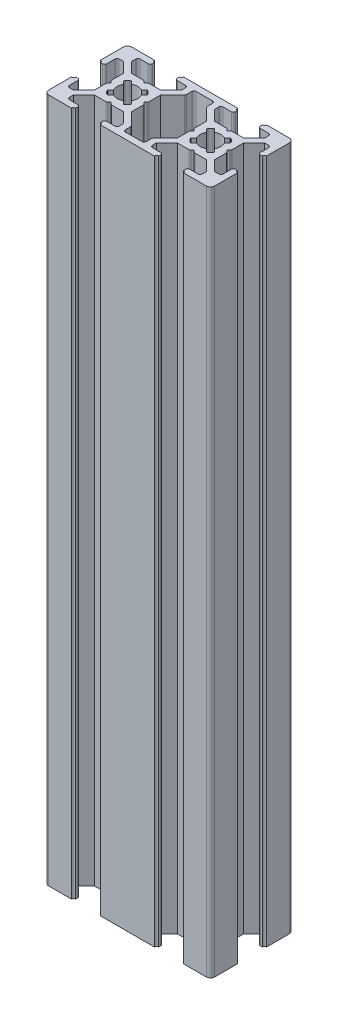
from build123d import *

# Parameters (mm, degrees)
BOSS_EXTRUDE1_DEPTH = 165
FILLET1_R           = 1
FILLET2_R           = 0.5
FILLET3_R           = 0.25
FILLET5_R           = 0.25
FILLET6_R           = 0.5
FILLET7_R           = 0.5
FILLET8_R           = 0.5


with BuildPart() as part:
    # Sketch2 → Boss-Extrude1 (new body)
    with BuildSketch(Plane(origin=(0, 0, 0), x_dir=(1, 0, 0), z_dir=(0, 1, 0))):
        with BuildLine():
            ThreePointArc((0, 13.5), (0.353553391, 13.353553391), (0.5, 13))
            Line((0.5, 13), (1.5, 13))
            Line((1.5, 13), (1.5, 16))
            Line((1.5, 16), (3, 16))
            Line((3, 16), (5.5, 13.5))
            Line((5.5, 13.5), (5.5, 10.5))
            Line((5.5, 10.5), (6, 10))
            Line((6, 10), (5.5, 9.5))
            Line((5.5, 9.5), (5.5, 6.5))
            Line((5.5, 6.5), (3, 4))
            Line((3, 4), (1.5, 4))
            Line((1.5, 4), (1.5, 7))
            Line((1.5, 7), (0.5, 7))
            ThreePointArc((0.5, 7), (0.353553391, 6.646446609), (0, 6.5))
            Line((0, 6.5), (0, 0))
            Line((0, 0), (6.5, 0))
            ThreePointArc((6.5, 0), (6.646446609, 0.353553391), (7, 0.5))
            Line((7, 0.5), (7, 1.5))
            Line((7, 1.5), (4, 1.5))
            Line((4, 1.5), (4, 3))
            Line((4, 3), (6.5, 5.5))
            Line((6.5, 5.5), (9.5, 5.5))
            Line((9.5, 5.5), (10, 6))
            Line((10, 6), (10.5, 5.5))
            Line((10.5, 5.5), (13.5, 5.5))
            Line((13.5, 5.5), (16, 3))
            Line((16, 3), (16, 1.5))
            Line((16, 1.5), (13, 1.5))
            Line((13, 1.5), (13, 0.5))
            ThreePointArc((13, 0.5), (13.353553391, 0.353553391), (13.5, 0))
            Line((13.5, 0), (26.5, 0))
            ThreePointArc((26.5, 0), (26.646446609, 0.353553391), (27, 0.5))
            Line((27, 0.5), (27, 1.5))
            Line((27, 1.5), (24, 1.5))
            Line((24, 1.5), (24, 3))
            Line((24, 3), (26.5, 5.5))
            Line((26.5, 5.5), (29.5, 5.5))
            Line((29.5, 5.5), (30, 6))
            Line((30, 6), (30.5, 5.5))
            Line((30.5, 5.5), (33.5, 5.5))
            Line((33.5, 5.5), (36, 3))
            Line((36, 3), (36, 1.5))
            Line((36, 1.5), (33, 1.5))
            Line((33, 1.5), (33, 0.5))
            ThreePointArc((33, 0.5), (33.353553391, 0.353553391), (33.5, 0))
            Line((33.5, 0), (40, 0))
            Line((40, 0), (40, 6.5))
            ThreePointArc((40, 6.5), (39.646446609, 6.646446609), (39.5, 7))
            Line((39.5, 7), (38.5, 7))
            Line((38.5, 7), (38.5, 4))
            Line((38.5, 4), (37, 4))
            Line((37, 4), (34.5, 6.5))
            Line((34.5, 6.5), (34.5, 9.5))
            Line((34.5, 9.5), (34, 10))
            Line((34, 10), (34.5, 10.5))
            Line((34.5, 10.5), (34.5, 13.5))
            Line((34.5, 13.5), (37, 16))
            Line((37, 16), (38.5, 16))
            Line((38.5, 16), (38.5, 13))
            Line((38.5, 13), (39.5, 13))
            ThreePointArc((39.5, 13), (39.646446609, 13.353553391), (40, 13.5))
            Line((40, 13.5), (40, 20))
            Line((40, 20), (33.5, 20))
            ThreePointArc((33.5, 20), (33.353553391, 19.646446609), (33, 19.5))
            Line((33, 19.5), (33, 18.5))
            Line((33, 18.5), (36, 18.5))
            Line((36, 18.5), (36, 17))
            Line((36, 17), (33.5, 14.5))
            Line((33.5, 14.5), (30.5, 14.5))
            Line((30.5, 14.5), (30, 14))
            Line((30, 14), (29.5, 14.5))
            Line((29.5, 14.5), (26.5, 14.5))
            Line((26.5, 14.5), (24, 17))
            Line((24, 17), (24, 18.5))
            Line((24, 18.5), (27, 18.5))
            Line((27, 18.5), (27, 19.5))
            ThreePointArc((27, 19.5), (26.646446609, 19.646446609), (26.5, 20))
            Line((26.5, 20), (13.5, 20))
            ThreePointArc((13.5, 20), (13.353553391, 19.646446609), (13, 19.5))
            Line((13, 19.5), (13, 18.5))
            Line((13, 18.5), (16, 18.5))
            Line((16, 18.5), (16, 17))
            Line((16, 17), (13.5, 14.5))
            Line((13.5, 14.5), (10.5, 14.5))
            Line((10.5, 14.5), (10, 14))
            Line((10, 14), (9.5, 14.5))
            Line((9.5, 14.5), (6.5, 14.5))
            Line((6.5, 14.5), (4, 17))
            Line((4, 17), (4, 18.5))
            Line((4, 18.5), (7, 18.5))
            Line((7, 18.5), (7, 19.5))
            ThreePointArc((7, 19.5), (6.646446609, 19.646446609), (6.5, 20))
            Line((6.5, 20), (0, 20))
            Line((0, 20), (0, 13.5))
        make_face()
        with BuildLine():
            Line((11.195582496, 12.195582496), (12, 13))
            Line((12, 13), (13, 12))
            Line((13, 12), (12.195582496, 11.195582496))
            ThreePointArc((12.195582496, 11.195582496), (12.422700584, 10.616864556), (12.5, 10))
            ThreePointArc((12.5, 10), (12.422700584, 9.383135444), (12.195582496, 8.804417504))
            Line((12.195582496, 8.804417504), (13, 8))
            Line((13, 8), (12, 7))
            Line((12, 7), (11.195582496, 7.804417504))
            ThreePointArc((11.195582496, 7.804417504), (10, 7.5), (8.804417504, 7.804417504))
            Line((8.804417504, 7.804417504), (8, 7))
            Line((8, 7), (7, 8))
            Line((7, 8), (7.804417504, 8.804417504))
            ThreePointArc((7.804417504, 8.804417504), (7.5, 10), (7.804417504, 11.195582496))
            Line((7.804417504, 11.195582496), (7, 12))
            Line((7, 12), (8, 13))
            Line((8, 13), (8.804417504, 12.195582496))
            ThreePointArc((8.804417504, 12.195582496), (10, 12.5), (11.195582496, 12.195582496))
        make_face(mode=Mode.SUBTRACT)
        Polygon((17.5, 16.5), (17.5, 18.5), (22.5, 18.5), (22.5, 16.5), (25.5, 13.5), (25.5, 10.5), (26, 10), (25.5, 9.5), (25.5, 6.5), (22.5, 3.5), (22.5, 1.5), (17.5, 1.5), (17.5, 3.5), (14.5, 6.5), (14.5, 9.5), (14, 10), (14.5, 10.5), (14.5, 13.5), align=None, mode=Mode.SUBTRACT)
        with BuildLine():
            Line((28.804417504, 7.804417504), (28, 7))
            Line((28, 7), (27, 8))
            Line((27, 8), (27.804417504, 8.804417504))
            ThreePointArc((27.804417504, 8.804417504), (27.5, 10), (27.804417504, 11.195582496))
            Line((27.804417504, 11.195582496), (27, 12))
            Line((27, 12), (28, 13))
            Line((28, 13), (28.804417504, 12.195582496))
            ThreePointArc((28.804417504, 12.195582496), (30, 12.5), (31.195582496, 12.195582496))
            Line((31.195582496, 12.195582496), (32, 13))
            Line((32, 13), (33, 12))
            Line((33, 12), (32.195582496, 11.195582496))
            ThreePointArc((32.195582496, 11.195582496), (32.422700584, 10.616864556), (32.5, 10))
            ThreePointArc((32.5, 10), (32.422700584, 9.383135444), (32.195582496, 8.804417504))
            Line((32.195582496, 8.804417504), (33, 8))
            Line((33, 8), (32, 7))
            Line((32, 7), (31.195582496, 7.804417504))
            ThreePointArc((31.195582496, 7.804417504), (30, 7.5), (28.804417504, 7.804417504))
        make_face(mode=Mode.SUBTRACT)
    extrude(amount=BOSS_EXTRUDE1_DEPTH)

    # Fillet1
    fillet1_edges = [part.edges().sort_by_distance(p)[0] for p in [
        (40, 82.5, 0),
        (0, 82.5, 0),
        (0, 82.5, -20),
        (40, 82.5, -20),
    ]]
    fillet(fillet1_edges, radius=FILLET1_R)

    # Fillet2
    fillet2_edges = [part.edges().sort_by_distance(p)[0] for p in [
        (7, 82.5, -18.5),
        (4, 82.5, -18.5),
        (9.5, 82.5, -14.5),
        (10.5, 82.5, -14.5),
        (16, 82.5, -18.5),
        (13, 82.5, -18.5),
    ]]
    fillet(fillet2_edges, radius=FILLET2_R)

    # Fillet3
    fillet3_edges = [part.edges().sort_by_distance(p)[0] for p in [
        (13, 82.5, -12),
        (12, 82.5, -13),
        (8, 82.5, -13),
        (7, 82.5, -12),
        (7, 82.5, -8),
        (8, 82.5, -7),
        (12, 82.5, -7),
        (13, 82.5, -8),
    ]]
    fillet(fillet3_edges, radius=FILLET3_R)

    # Fillet5
    fillet5_edges = [part.edges().sort_by_distance(p)[0] for p in [
        (27, 82.5, -8),
        (28, 82.5, -7),
        (32, 82.5, -7),
        (33, 82.5, -8),
        (33, 82.5, -12),
        (32, 82.5, -13),
        (28, 82.5, -13),
        (27, 82.5, -12),
    ]]
    fillet(fillet5_edges, radius=FILLET5_R)

    # Fillet6
    fillet6_edges = [part.edges().sort_by_distance(p)[0] for p in [
        (33, 82.5, -1.5),
        (36, 82.5, -1.5),
        (30.5, 82.5, -5.5),
        (29.5, 82.5, -5.5),
        (24, 82.5, -1.5),
        (27, 82.5, -1.5),
        (13, 82.5, -1.5),
        (16, 82.5, -1.5),
        (10.5, 82.5, -5.5),
        (9.5, 82.5, -5.5),
        (4, 82.5, -1.5),
        (7, 82.5, -1.5),
        (1.5, 82.5, -7),
        (1.5, 82.5, -4),
        (5.5, 82.5, -9.5),
        (5.5, 82.5, -10.5),
        (1.5, 82.5, -16),
        (1.5, 82.5, -13),
        (27, 82.5, -18.5),
        (24, 82.5, -18.5),
        (29.5, 82.5, -14.5),
        (30.5, 82.5, -14.5),
        (36, 82.5, -18.5),
        (33, 82.5, -18.5),
        (38.5, 82.5, -13),
        (38.5, 82.5, -16),
        (34.5, 82.5, -10.5),
        (34.5, 82.5, -9.5),
        (38.5, 82.5, -4),
        (38.5, 82.5, -7),
    ]]
    fillet(fillet6_edges, radius=FILLET6_R)

    # Fillet7
    fillet7_edges = [part.edges().sort_by_distance(p)[0] for p in [
        (22.5, 82.5, -16.5),
        (22.5, 82.5, -18.5),
        (17.5, 82.5, -18.5),
        (17.5, 82.5, -16.5),
        (17.5, 82.5, -3.5),
        (17.5, 82.5, -1.5),
        (22.5, 82.5, -1.5),
        (22.5, 82.5, -3.5),
    ]]
    fillet(fillet7_edges, radius=FILLET7_R)

    # Fillet8
    fillet8_edges = [part.edges().sort_by_distance(p)[0] for p in [
        (25.5, 82.5, -10.5),
        (14.5, 82.5, -10.5),
        (14.5, 82.5, -9.5),
        (25.5, 82.5, -9.5),
    ]]
    fillet(fillet8_edges, radius=FILLET8_R)


solid = part.part
